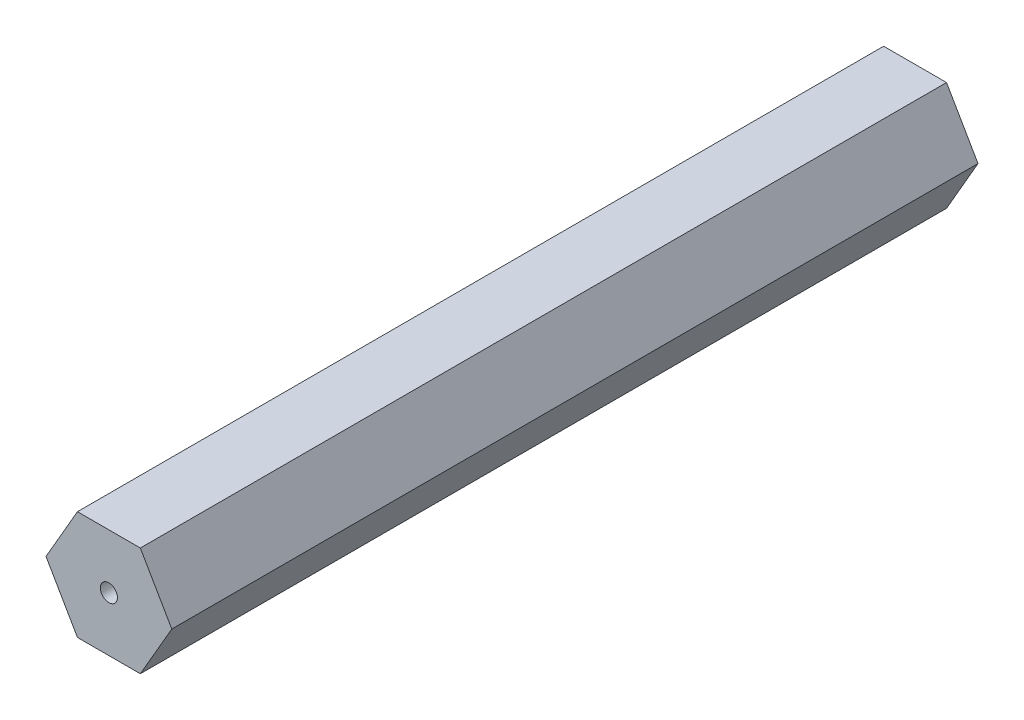
from build123d import *

# Parameters (mm, degrees)
BOSS_EXTRUDE1_DEPTH = 94
SKETCH2_R           = 1
CUT_EXTRUDE1_DEPTH  = 95


with BuildPart() as part:
    # Sketch1 → Boss-Extrude1 (new body)
    with BuildSketch(Plane.XY):
        Polygon((7.332348419, 0), (3.666174209, 6.35), (-3.666174209, 6.35), (-7.332348419, 0), (-3.666174209, -6.35), (3.666174209, -6.35), align=None)
    extrude(amount=BOSS_EXTRUDE1_DEPTH)

    # Sketch2 → Cut-Extrude1 (cut, through all)
    with BuildSketch(Plane.XY.offset(94)):
        Circle(SKETCH2_R)
    extrude(amount=-CUT_EXTRUDE1_DEPTH, mode=Mode.SUBTRACT)


solid = part.part
